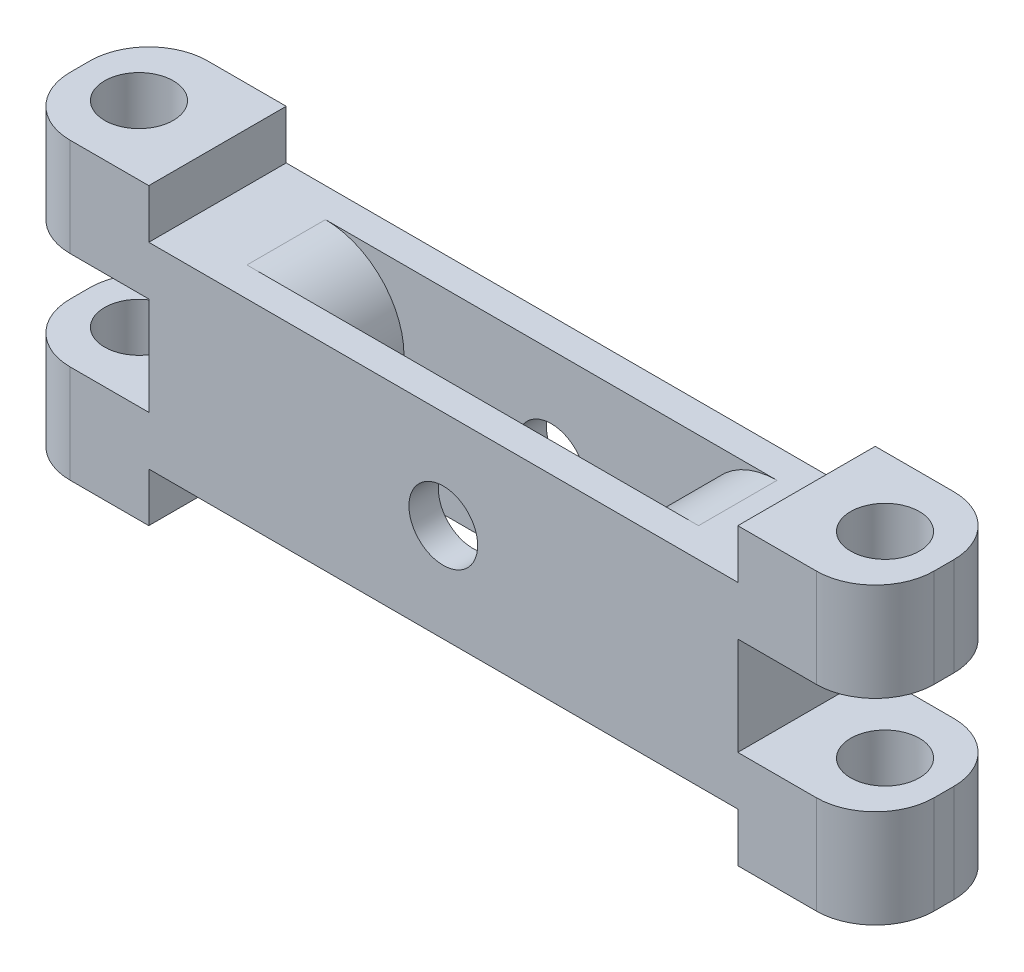
from build123d import *

# Parameters (mm, degrees)
SKETCH1_W            = 30
SKETCH1_H            = 7
BOSS_EXTRUDE1_DEPTH  = 10
SKETCH2_W            = 15
SKETCH2_H            = 4
CUT_EXTRUDE1_DEPTH   = 10
SKETCH3_R            = 1.75
CUT_EXTRUDE2_DEPTH   = 10
FILLET1_R            = 4
SKETCH4_W            = 7
SKETCH4_H            = 15
BOSS_EXTRUDE2_DEPTH  = 7
SKETCH5_W            = 7
SKETCH5_H            = 5
CUT_EXTRUDE3_DEPTH   = 7
SKETCH6_R            = 1.75
CUT_EXTRUDE4_DEPTH   = 16
FILLET2_R            = 3
FILLET2_OF_MIRROR1_R = 3


with BuildPart() as part:
    # Sketch1 → Boss-Extrude1 (new body)
    with BuildSketch(Plane(origin=(0, 0, 0), x_dir=(1, 0, 0), z_dir=(0, 1, 0))):
        Rectangle(SKETCH1_W, SKETCH1_H)
    extrude(amount=BOSS_EXTRUDE1_DEPTH)

    # Sketch2 → Cut-Extrude1 (cut)
    with BuildSketch(Plane(origin=(0, 10, 0), x_dir=(1, 0, 0), z_dir=(0, 1, 0))):
        Rectangle(SKETCH2_W, SKETCH2_H)
    extrude(amount=-CUT_EXTRUDE1_DEPTH, mode=Mode.SUBTRACT)

    # Sketch3 → Cut-Extrude2 (cut)
    with BuildSketch(Plane.XY.offset(3.5)):
        with Locations((0, 5)):
            Circle(SKETCH3_R)
    extrude(amount=-CUT_EXTRUDE2_DEPTH, mode=Mode.SUBTRACT)

    # Fillet1
    fillet1_edges = [part.edges().sort_by_distance(p)[0] for p in [
        (7.5, 0, 0),
        (-7.5, 0, 0),
        (7.5, 10, 0),
        (-7.5, 10, 0),
    ]]
    fillet(fillet1_edges, radius=FILLET1_R)

    # Sketch4 → Boss-Extrude2 (add)
    with BuildSketch(Plane(origin=(15, 0, 0), x_dir=(0, 0, -1), z_dir=(1, 0, 0))):
        with Locations((0, 5)):
            Rectangle(SKETCH4_W, SKETCH4_H)
    boss_extrude2 = extrude(amount=BOSS_EXTRUDE2_DEPTH)

    # Sketch5 → Cut-Extrude3 (cut)
    with BuildSketch(Plane(origin=(22, 0, 0), x_dir=(0, 0, -1), z_dir=(1, 0, 0))):
        with Locations((0, 5)):
            Rectangle(SKETCH5_W, SKETCH5_H)
    cut_extrude3 = extrude(amount=-CUT_EXTRUDE3_DEPTH, mode=Mode.SUBTRACT)

    # Sketch6 → Cut-Extrude4 (cut, through all)
    with BuildSketch(Plane(origin=(0, 12.5, 0), x_dir=(1, 0, 0), z_dir=(0, 1, 0))):
        with Locations((19, 0)):
            Circle(SKETCH6_R)
    cut_extrude4 = extrude(amount=-CUT_EXTRUDE4_DEPTH, mode=Mode.SUBTRACT)

    # Fillet2
    fillet2_edges = [part.edges().sort_by_distance(p)[0] for p in [
        (22, 0, -3.5),
        (22, 10, 3.5),
        (22, 10, -3.5),
        (22, 0, 3.5),
    ]]
    fillet(fillet2_edges, radius=FILLET2_R)

    # Mirror1: Boss-Extrude2, Cut-Extrude3, Cut-Extrude4 across plane
    add(boss_extrude2.mirror(Plane(origin=(0, 0, 0), x_dir=(0, 0, 1), z_dir=(1, 0, 0))))
    add(cut_extrude3.mirror(Plane(origin=(0, 0, 0), x_dir=(0, 0, 1), z_dir=(1, 0, 0))), mode=Mode.SUBTRACT)
    add(cut_extrude4.mirror(Plane(origin=(0, 0, 0), x_dir=(0, 0, 1), z_dir=(1, 0, 0))), mode=Mode.SUBTRACT)

    # Fillet2 of Mirror1
    fillet2_of_mirror1_edges = [part.edges().sort_by_distance(p)[0] for p in [
        (-22, 0, -3.5),
        (-22, 10, 3.5),
        (-22, 10, -3.5),
        (-22, 0, 3.5),
    ]]
    fillet(fillet2_of_mirror1_edges, radius=FILLET2_OF_MIRROR1_R)


solid = part.part
